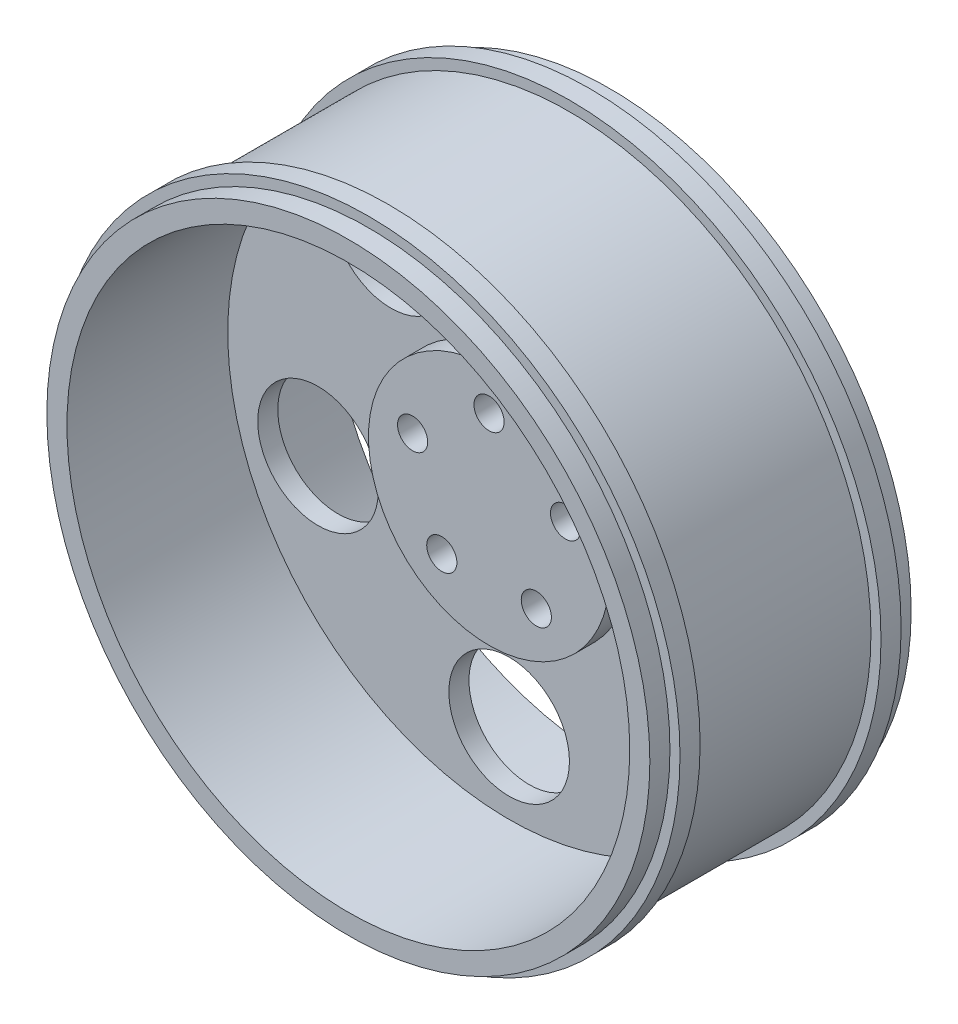
from build123d import *

# Parameters (mm, degrees)
SKETCH8_R               = 7.5
CUT_EXTRUDE1_DEPTH      = 71
CUT_EXTRUDE1_DEPTH_BACK = 61
SKETCH9_R               = 30
CUT_EXTRUDE2_DEPTH      = 81
CUT_EXTRUDE2_DEPTH_BACK = 51


with BuildPart() as part:
    # Sketch6 → Revolve3 (revolve)
    with BuildSketch(Plane(origin=(0, 0, 0), x_dir=(0, 0, -1), z_dir=(1, 0, 0))):
        Polygon((0, 0), (10, 0), (10, 140), (50, 140), (50, 150), (40, 150), (40, 155), (30, 155), (30, 150), (-60, 150), (-60, 155), (-70, 155), (-70, 150), (-80, 150), (-80, 140), (0, 140), (0, 60), (-10, 60), (-10, 0), align=None)
    revolve(axis=Axis((0, 0, 10), (0, 0, -1)))

    # Sketch8 → Cut-Extrude1 (cut, two sides)
    with BuildSketch(Plane.XY.offset(10)) as cut_extrude1_sk:
        with Locations((0, 40)):
            Circle(SKETCH8_R)
        with Locations((38.042260652, 12.360679775)):
            Circle(SKETCH8_R)
        with Locations((23.511410092, -32.360679775)):
            Circle(SKETCH8_R)
        with Locations((-23.511410092, -32.360679775)):
            Circle(SKETCH8_R)
        with Locations((-38.042260652, 12.360679775)):
            Circle(SKETCH8_R)
    extrude(amount=CUT_EXTRUDE1_DEPTH, mode=Mode.SUBTRACT)
    extrude(cut_extrude1_sk.sketch, amount=-CUT_EXTRUDE1_DEPTH_BACK, mode=Mode.SUBTRACT)

    # Sketch9 → Cut-Extrude2 (cut, two sides)
    with BuildSketch(Plane.XY) as cut_extrude2_sk:
        with Locations((0, -100)):
            Circle(SKETCH9_R)
        with Locations((-95.10565163, -30.901699437)):
            Circle(SKETCH9_R)
        with Locations((-58.778525229, 80.901699437)):
            Circle(SKETCH9_R)
        with Locations((58.778525229, 80.901699437)):
            Circle(SKETCH9_R)
        with Locations((95.10565163, -30.901699437)):
            Circle(SKETCH9_R)
    extrude(amount=CUT_EXTRUDE2_DEPTH, mode=Mode.SUBTRACT)
    extrude(cut_extrude2_sk.sketch, amount=-CUT_EXTRUDE2_DEPTH_BACK, mode=Mode.SUBTRACT)


solid = part.part
